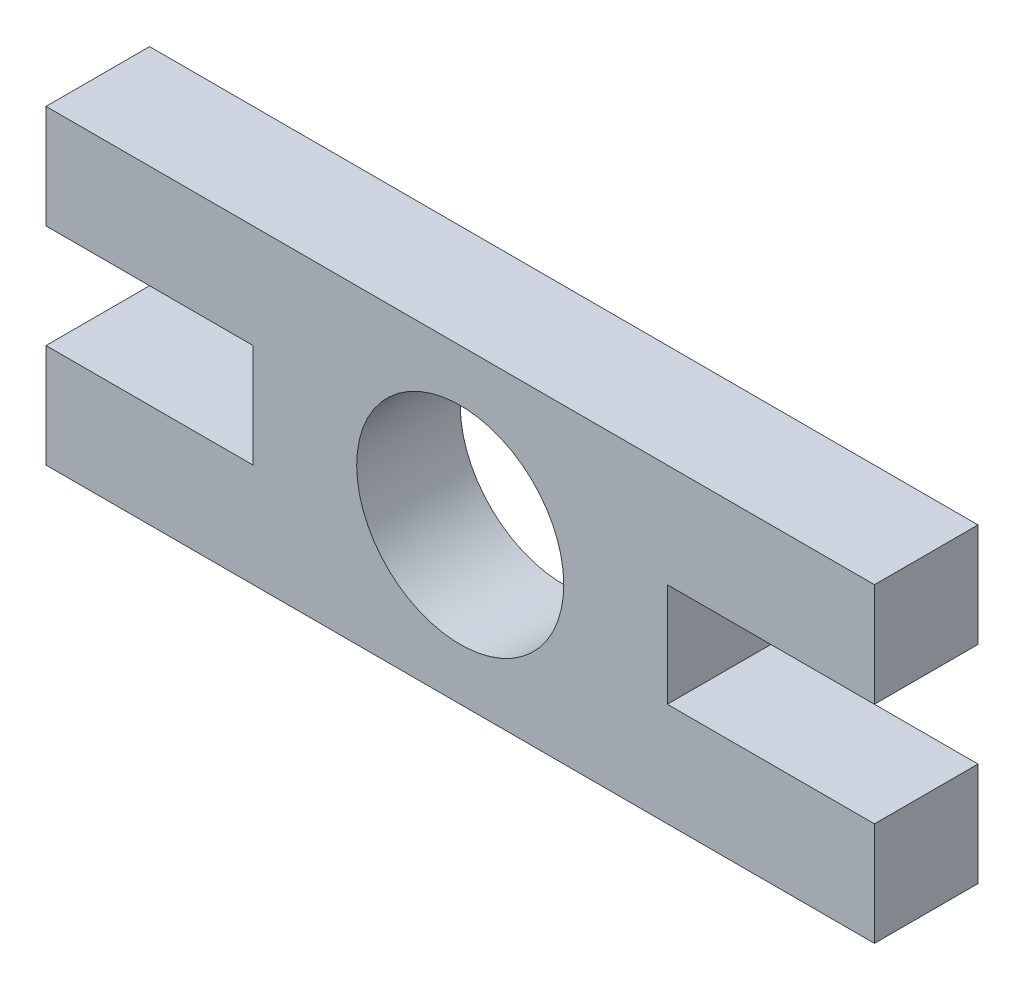
from build123d import *

# Parameters (mm, degrees)
SKETCH2_W           = 25.4
SKETCH2_H           = 12.7
BOSS_EXTRUDE1_DEPTH = 21.59
SKETCH3_W           = 12.7
SKETCH3_H           = 7.62
BOSS_EXTRUDE2_DEPTH = 12.7
SKETCH4_R           = 6.35
CUT_EXTRUDE1_DEPTH  = 13.7
SKETCH6_W           = 50.8
SKETCH6_H           = 12.7
CUT_EXTRUDE2_DEPTH  = 1.27
SKETCH7_W           = 50.8
SKETCH7_H           = 12.7
CUT_EXTRUDE3_DEPTH  = 1.27
SKETCH8_W           = 50.8
SKETCH8_H           = 19.05
CUT_EXTRUDE4_DEPTH  = 6.35


with BuildPart() as part:
    # Sketch2 → Boss-Extrude1 (new body)
    with BuildSketch(Plane(origin=(0, 0, 0), x_dir=(1, 0, 0), z_dir=(0, 1, 0))):
        with Locations((1.985818182, -2.085878788)):
            Rectangle(SKETCH2_W, SKETCH2_H)
    extrude(amount=BOSS_EXTRUDE1_DEPTH)

    # Sketch3 → Boss-Extrude2 (add)
    with BuildSketch(Plane.XY.offset(8.435878788)):
        with Locations((-17.064181818, 17.78)):
            Rectangle(SKETCH3_W, SKETCH3_H)
        with Locations((-17.064181818, 3.81)):
            Rectangle(SKETCH3_W, SKETCH3_H)
        with Locations((21.035818182, 17.78)):
            Rectangle(SKETCH3_W, SKETCH3_H)
        with Locations((21.035818182, 3.81)):
            Rectangle(SKETCH3_W, SKETCH3_H)
    extrude(amount=-BOSS_EXTRUDE2_DEPTH)

    # Sketch4 → Cut-Extrude1 (cut, through all)
    with BuildSketch(Plane.XY.offset(8.435878788)):
        with Locations((1.985818182, 10.795)):
            Circle(SKETCH4_R)
    extrude(amount=-CUT_EXTRUDE1_DEPTH, mode=Mode.SUBTRACT)

    # Sketch6 → Cut-Extrude2 (cut)
    with BuildSketch(Plane(origin=(0, 21.59, 0), x_dir=(1, 0, 0), z_dir=(0, 1, 0))):
        with Locations((1.985818182, -2.085878788)):
            Rectangle(SKETCH6_W, SKETCH6_H)
    extrude(amount=-CUT_EXTRUDE2_DEPTH, mode=Mode.SUBTRACT)

    # Sketch7 → Cut-Extrude3 (cut)
    with BuildSketch(Plane.XZ):
        with Locations((1.985818182, 2.085878788)):
            Rectangle(SKETCH7_W, SKETCH7_H)
    extrude(amount=-CUT_EXTRUDE3_DEPTH, mode=Mode.SUBTRACT)

    # Sketch8 → Cut-Extrude4 (cut)
    with BuildSketch(Plane.XY.offset(8.435878788)):
        with Locations((1.985818182, 10.795)):
            Rectangle(SKETCH8_W, SKETCH8_H)
    extrude(amount=-CUT_EXTRUDE4_DEPTH, mode=Mode.SUBTRACT)


solid = part.part
